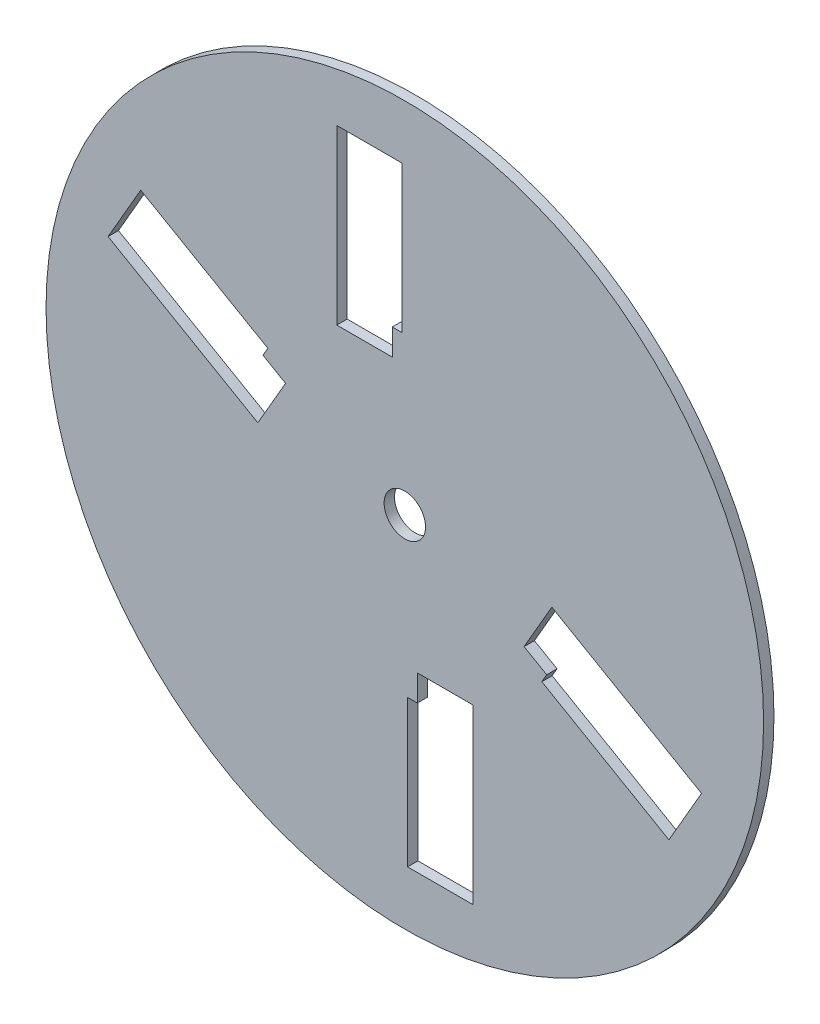
from build123d import *

# Parameters (mm, degrees)
SKETCH1_R           = 110
SKETCH1_R_2         = 6.35
BOSS_EXTRUDE1_DEPTH = 1.5875


with BuildPart() as part:
    # Sketch1 → Boss-Extrude1 (new body, symmetric)
    with BuildSketch(Plane.XY):
        Circle(SKETCH1_R)
        Circle(SKETCH1_R_2, mode=Mode.SUBTRACT)
        Polygon((-6.35, 40), (-3.85, 40), (-3.85, 48), (-0.85, 48), (-0.85, 93), (-20.85, 93), (-20.85, 40), (-18.35, 40), align=None, mode=Mode.SUBTRACT)
        Polygon((6.35, -40), (3.85, -40), (3.85, -48), (0.85, -48), (0.85, -93), (20.85, -93), (20.85, -40), (18.35, -40), align=None, mode=Mode.SUBTRACT)
        Polygon((37.816016151, -14.500738686), (36.566016151, -16.665802195), (43.494219382, -20.665802195), (41.994219382, -23.263878407), (80.965362552, -45.763878407), (90.965362552, -28.443370331), (45.066016151, -1.943370331), (43.816016151, -4.108433841), align=None, mode=Mode.SUBTRACT)
        Polygon((-37.816016151, 14.500738686), (-36.566016151, 16.665802195), (-43.494219382, 20.665802195), (-41.994219382, 23.263878407), (-80.965362552, 45.763878407), (-90.965362552, 28.443370331), (-45.066016151, 1.943370331), (-43.816016151, 4.108433841), align=None, mode=Mode.SUBTRACT)
    extrude(amount=BOSS_EXTRUDE1_DEPTH, both=True)


solid = part.part
